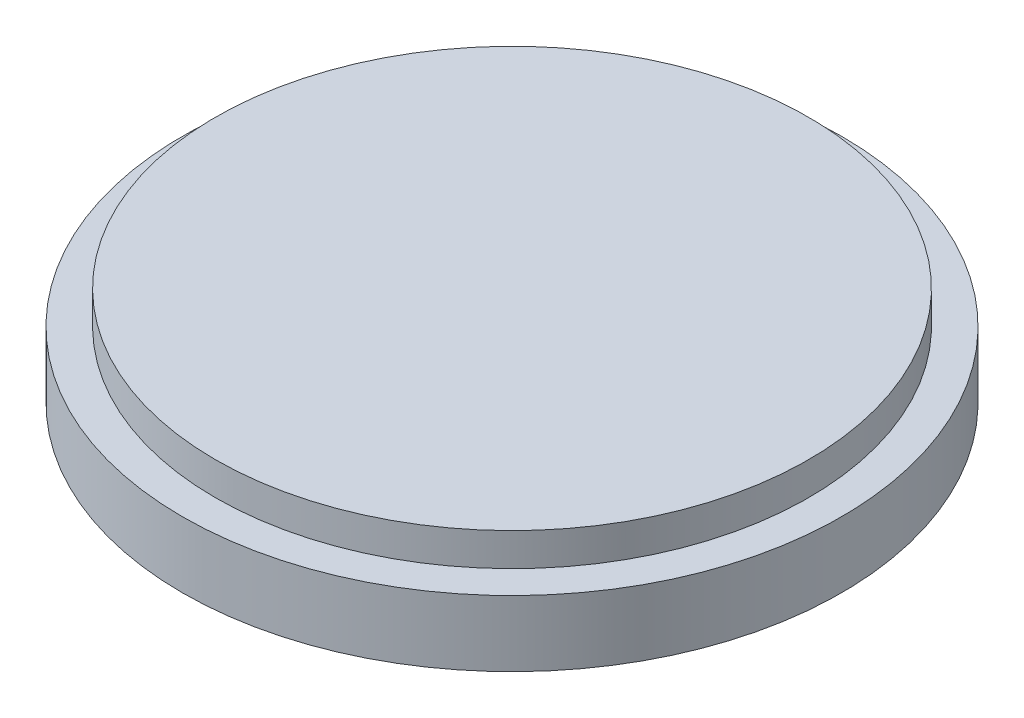
from build123d import *

# Parameters (mm, degrees)
CROQUIS1_R              = 25
SALIENTE_EXTRUIR1_DEPTH = 5
CROQUIS2_R              = 22.5
SALIENTE_EXTRUIR2_DEPTH = 2.5


with BuildPart() as part:
    # Croquis1 → Saliente-Extruir1 (new body)
    with BuildSketch(Plane(origin=(0, 0, 0), x_dir=(1, 0, 0), z_dir=(0, 1, 0))):
        Circle(CROQUIS1_R)
    extrude(amount=SALIENTE_EXTRUIR1_DEPTH)

    # Croquis2 → Saliente-Extruir2 (add)
    with BuildSketch(Plane(origin=(0, 5, 0), x_dir=(1, 0, 0), z_dir=(0, 1, 0))):
        Circle(CROQUIS2_R)
    extrude(amount=SALIENTE_EXTRUIR2_DEPTH)


solid = part.part
